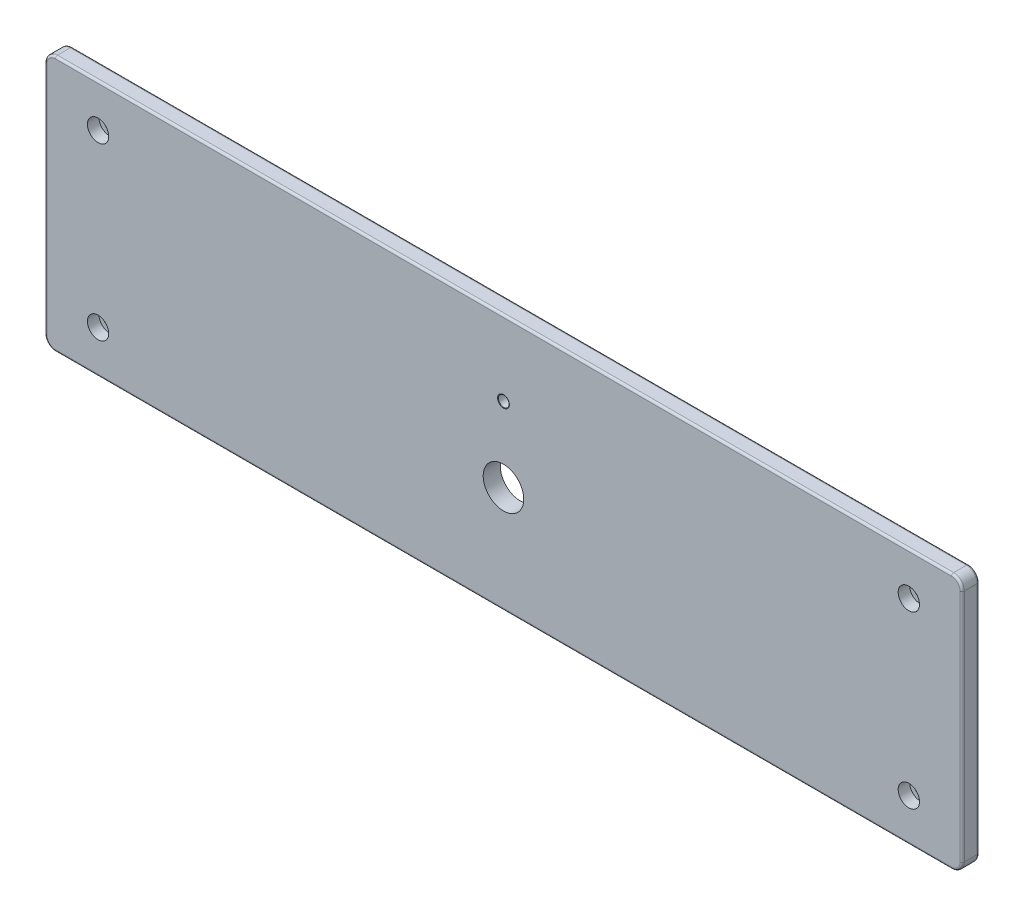
from build123d import *

# Parameters (mm, degrees)
SKETCH1_W                                           = 430
SKETCH1_H                                           = 120
EXTRUDE1_DEPTH                                      = 8
FILLET1_R                                           = 5
FILLET2_R                                           = 1
F_5_0_5_DIAMETER_HOLE1_D                            = 5
F_19_0_19_DIAMETER_HOLE1_D                          = 19
CHAMFER1_SIZE                                       = 0.25
CHAMFER1_SIZE2                                      = 0.144337567
CBORE_FOR_M5_HEX_SOCKET_HEAD_CAP_SCREW1_D           = 5.5
CBORE_FOR_M5_HEX_SOCKET_HEAD_CAP_SCREW1_CBORE_D     = 10
CBORE_FOR_M5_HEX_SOCKET_HEAD_CAP_SCREW1_CBORE_DEPTH = 5.4


with BuildPart() as part:
    # Sketch1 → Extrude1 (new body)
    with BuildSketch(Plane.XY):
        with Locations((215, 60)):
            Rectangle(SKETCH1_W, SKETCH1_H)
    extrude(amount=EXTRUDE1_DEPTH)

    # Fillet1
    fillet1_edges = [part.edges().sort_by_distance(p)[0] for p in [
        (0, 120, 4),
        (430, 120, 4),
        (430, 0, 4),
        (0, 0, 4),
    ]]
    fillet(fillet1_edges, radius=FILLET1_R)

    # Fillet2
    fillet2_edges = [part.edges().sort_by_distance(p)[0] for p in [
        (215, 0, 0),
        (215, 0, 8),
        (0, 60, 0),
        (215, 120, 0),
        (430, 60, 0),
        (1.464466094, 118.535533906, 0),
        (428.535533906, 118.535533906, 0),
        (428.535533906, 1.464466094, 0),
        (1.464466094, 1.464466094, 0),
        (0, 60, 8),
        (430, 60, 8),
        (215, 120, 8),
        (1.464466094, 118.535533906, 8),
        (428.535533906, 118.535533906, 8),
        (428.535533906, 1.464466094, 8),
        (1.464466094, 1.464466094, 8),
    ]]
    fillet(fillet2_edges, radius=FILLET2_R)

    # Ø5.0 (5) Diameter Hole1 (through all)
    with Locations(Plane(origin=(215, 85, 8), x_dir=(1, 0, 0), z_dir=(0, 0, 1))):
        with Locations((0, 0)):
            Hole(F_5_0_5_DIAMETER_HOLE1_D / 2)

    # Ø19.0 (19) Diameter Hole1 (through all)
    with Locations(Plane(origin=(215, 50, 8), x_dir=(1, 0, 0), z_dir=(0, 0, 1))):
        with Locations((0, 0)):
            Hole(F_19_0_19_DIAMETER_HOLE1_D / 2)

    # Chamfer1
    chamfer1_edges = [part.edges().sort_by_distance(p)[0] for p in [
        (217.5, 85, 8),
    ]]
    chamfer1_side = [part.faces().sort_by_distance(p)[0] for p in [
        (215, 60.046713467, 8),
    ]]
    chamfer(chamfer1_edges, length=CHAMFER1_SIZE, length2=CHAMFER1_SIZE2, reference=chamfer1_side[0])

    # CBORE for M5 Hex Socket Head Cap Screw1 (through all)
    with Locations(Plane(origin=(25, 20, 8), x_dir=(1, 0, 0), z_dir=(0, 0, 1))):
        with Locations((0, 0), (0, 80), (380, 0), (380, 80)):
            CounterBoreHole(CBORE_FOR_M5_HEX_SOCKET_HEAD_CAP_SCREW1_D / 2, CBORE_FOR_M5_HEX_SOCKET_HEAD_CAP_SCREW1_CBORE_D / 2, CBORE_FOR_M5_HEX_SOCKET_HEAD_CAP_SCREW1_CBORE_DEPTH)


solid = part.part
